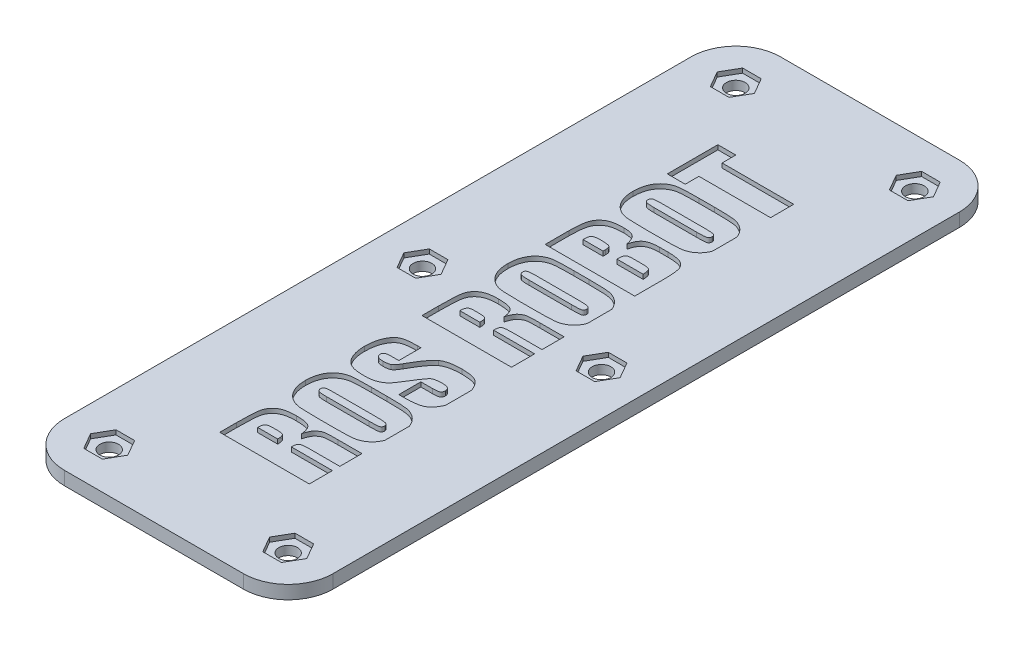
from build123d import *

# Parameters (mm, degrees)
SKETCH1_W           = 60
SKETCH1_H           = 160
BOSS_EXTRUDE1_DEPTH = 3
SKETCH2_R           = 2.09
CUT_EXTRUDE1_DEPTH  = 4
CUT_EXTRUDE2_DEPTH  = 1
FILLET1_R           = 10
CUT_EXTRUDE3_DEPTH  = 1


with BuildPart() as part:
    # Sketch1 → Boss-Extrude1 (new body)
    with BuildSketch(Plane(origin=(0, 0, 0), x_dir=(1, 0, 0), z_dir=(0, 1, 0))):
        Rectangle(SKETCH1_W, SKETCH1_H)
    extrude(amount=BOSS_EXTRUDE1_DEPTH)

    # Sketch2 → Cut-Extrude1 (cut, through all)
    with BuildSketch(Plane(origin=(0, 3, 0), x_dir=(1, 0, 0), z_dir=(0, 1, 0))):
        with Locations((-20, -70)):
            Circle(SKETCH2_R)
        with Locations((-20, 0)):
            Circle(SKETCH2_R)
        with Locations((-20, 70)):
            Circle(SKETCH2_R)
    cut_extrude1 = extrude(amount=-CUT_EXTRUDE1_DEPTH, mode=Mode.SUBTRACT)

    # Mirror1: Cut-Extrude1 across plane
    add(cut_extrude1.mirror(Plane(origin=(0, 0, 0), x_dir=(0, 0, 1), z_dir=(1, 0, 0))), mode=Mode.SUBTRACT)

    # Sketch3 → Cut-Extrude2 (cut)
    with BuildSketch(Plane(origin=(0, 3, 0), x_dir=(1, 0, 0), z_dir=(0, 1, 0))):
        with BuildLine():
            Line((-10, -55.294117647), (10, -55.294117647))
            Line((10, -55.294117647), (10, -50.117647059))
            Line((10, -50.117647059), (0.823529412, -50.117647059))
            add(Edge.make_bspline(
                [(3.235294118, -48.470588235), (2.989040814, -48.472629573), (2.639050732, -48.472609959), (2.199316231, -48.504803837), (1.926897066, -48.533164663), (1.692438703, -48.569281782), (1.49574074, -48.610523448), (1.339038243, -48.665722106), (1.214579141, -48.728929145), (1.113981631, -48.811228735), (1.03929987, -48.923342767), (0.966657804, -49.054244329), (0.919353851, -49.217915347), (0.873311477, -49.403659462), (0.835597841, -49.707286412), (0.823973747, -49.948124989), (0.823529412, -50.117647059)],
                knots=[0, 0, 0, 0, 0.208735031, 0.296167179, 0.37344265, 0.440694545, 0.497112652, 0.543415123, 0.581035154, 0.614932476, 0.652105749, 0.694367553, 0.74131732, 0.795712192, 0.856498699, 1, 1, 1, 1], degree=3))
            Line((3.235294118, -48.470588235), (10, -48.470588235))
            Line((10, -48.470588235), (10, -43.529411765))
            Line((10, -43.529411765), (4.658088235, -43.529411765))
            add(Edge.make_bspline(
                [(-0.573529412, -46.408088235), (-0.508186487, -46.169202547), (-0.415807847, -45.822748493), (-0.253576942, -45.392429256), (-0.12424053, -45.117359412), (0.008181693, -44.872188688), (0.146242268, -44.65674583), (0.298199184, -44.475211831), (0.505595072, -44.279090918), (0.769482386, -44.085338589), (1.073939288, -43.890136431), (1.366818297, -43.747197915), (1.616256033, -43.665317475), (1.84380423, -43.628386957), (2.070329283, -43.598146442), (2.357684941, -43.579047523), (2.703272021, -43.560390596), (3.107774826, -43.546616069), (3.76580814, -43.52957415), (4.289261909, -43.534840608), (4.658088235, -43.529411765)],
                knots=[0, 0, 0, 0, 0.110210274, 0.159198398, 0.204303993, 0.245275902, 0.283065073, 0.3178845, 0.350264175, 0.409777515, 0.463155522, 0.510931222, 0.554366277, 0.579275166, 0.613344402, 0.65597887, 0.707279948, 0.767268001, 0.835955663, 1, 1, 1, 1], degree=3))
            add(Edge.make_bspline(
                [(-4.617647059, -43.529411765), (-4.265347321, -43.523568214), (-3.759919224, -43.547429474), (-3.118182503, -43.602500182), (-2.707546117, -43.670971052), (-2.343153143, -43.74912541), (-2.023822753, -43.845927278), (-1.754303785, -43.967615545), (-1.524564876, -44.105726294), (-1.330409182, -44.274272382), (-1.160503413, -44.475701558), (-1.010392486, -44.712065683), (-0.880561748, -44.983524654), (-0.777601525, -45.29095197), (-0.646430718, -45.763349146), (-0.597468225, -46.144266225), (-0.573529412, -46.408088235)],
                knots=[0, 0, 0, 0, 0.183843892, 0.264214308, 0.336184648, 0.401092358, 0.45878306, 0.510056682, 0.55517248, 0.59828253, 0.64368343, 0.692329227, 0.744143255, 0.800414159, 0.861431347, 1, 1, 1, 1], degree=3))
            add(Edge.make_bspline(
                [(-10, -51.566176471), (-10.002073268, -50.993819944), (-9.992522011, -50.173782937), (-9.961770188, -49.130967301), (-9.934349846, -48.461579038), (-9.893765625, -47.867125834), (-9.846902044, -47.348485673), (-9.793813546, -46.905287107), (-9.727924289, -46.526534008), (-9.642203621, -46.192709029), (-9.529610049, -45.884608598), (-9.3956181, -45.589803188), (-9.228198446, -45.311726309), (-9.031642664, -45.052332013), (-8.815602269, -44.802348856), (-8.564597704, -44.574834978), (-8.290441128, -44.355921653), (-7.977684947, -44.158035206), (-7.6226227, -43.990685169), (-7.226287928, -43.847046859), (-6.786918244, -43.730527587), (-6.30511939, -43.640302786), (-5.579003966, -43.54780148), (-5.009887783, -43.534831682), (-4.617647059, -43.529411765)],
                knots=[0, 0, 0, 0, 0.148881435, 0.213302999, 0.271376625, 0.323137581, 0.368275921, 0.406826982, 0.439217091, 0.468211877, 0.496345732, 0.524443445, 0.552325136, 0.580568943, 0.609027807, 0.638127546, 0.668547056, 0.700208954, 0.734143472, 0.770447799, 0.809729999, 0.852243566, 0.897872275, 1, 1, 1, 1], degree=3))
            Line((-10, -51.566176471), (-10, -55.294117647))
        make_face()
        with BuildLine():
            Line((-2.235294118, -50.117647059), (-6.705882353, -50.117647059))
            add(Edge.make_bspline(
                [(-5.154411765, -48.470588235), (-5.418336948, -48.473249493), (-5.788234319, -48.491488459), (-6.208983424, -48.648984539), (-6.422021915, -48.813415334), (-6.552252293, -49.050216126), (-6.691331049, -49.479623299), (-6.700787332, -49.853765331), (-6.705882353, -50.117647059)],
                knots=[0, 0, 0, 0, 0.296724354, 0.405999103, 0.497474067, 0.590179394, 0.702696619, 1, 1, 1, 1], degree=3))
            Line((-5.154411765, -48.470588235), (-4.047794118, -48.470588235))
            add(Edge.make_bspline(
                [(-2.235294118, -50.117647059), (-2.2410209, -49.859031368), (-2.244911105, -49.494151793), (-2.359520163, -49.070270281), (-2.445519037, -48.867401357), (-2.55713594, -48.745711405), (-2.670238573, -48.667444045), (-2.820402185, -48.608189394), (-3.001543379, -48.557137957), (-3.215789469, -48.518214901), (-3.567218076, -48.475786698), (-3.849445649, -48.476158465), (-4.047794118, -48.470588235)],
                knots=[0, 0, 0, 0, 0.26299036, 0.361622752, 0.442866927, 0.481355846, 0.526610603, 0.580321924, 0.643299483, 0.716253842, 0.799640904, 1, 1, 1, 1], degree=3))
        make_face(mode=Mode.SUBTRACT)
        with BuildLine():
            add(Edge.make_bspline(
                [(10, -38.378083125), (9.980984118, -38.42752306), (9.878125419, -38.685696746), (9.665995506, -39.134570848), (9.29388391, -39.678742325), (8.86835261, -40.17166977), (8.369272434, -40.58621281), (7.832614548, -40.935288079), (7.264792336, -41.206088056), (6.674408532, -41.400035049), (6.156196354, -41.495437109), (5.704959011, -41.53554284), (5.307854377, -41.56519848), (4.85186231, -41.58999385), (4.338407042, -41.612881022), (3.765971372, -41.625929638), (2.887326127, -41.641512883), (2.198536957, -41.645759791), (1.720588235, -41.647058824)],
                knots=[0.224411446, 0.224411446, 0.224411446, 0.224411446, 0.237202779, 0.291504649, 0.343987522, 0.396025725, 0.44835046, 0.500180972, 0.550381919, 0.599920811, 0.649928359, 0.677302448, 0.709372201, 0.746150888, 0.787647262, 0.833562824, 0.884505076, 1, 1, 1, 1], degree=3))
            Line((10, -38.378083125), (10, -32.902336549))
            add(Edge.make_bspline(
                [(1.720588235, -29.647058824), (2.188717266, -29.651572048), (2.862792337, -29.648872672), (3.724400067, -29.662884644), (4.286760579, -29.683832297), (4.795587242, -29.69920585), (5.249009688, -29.725592699), (5.647384029, -29.754774686), (6.101645014, -29.796088836), (6.624952968, -29.881882502), (7.219368568, -30.068760168), (7.784773996, -30.331855104), (8.318358198, -30.667586355), (8.812591488, -31.069196806), (9.245882126, -31.546644343), (9.620320483, -32.087557394), (9.855282283, -32.552476311), (9.971898719, -32.831420628), (10, -32.902336549)],
                knots=[0, 0, 0, 0, 0.11310055, 0.162848353, 0.208171349, 0.249055911, 0.285827126, 0.317890363, 0.34555357, 0.396029061, 0.44565955, 0.495598169, 0.546282494, 0.597611279, 0.648954578, 0.701516088, 0.756070273, 0.774486187, 0.774486187, 0.774486187, 0.774486187], degree=3))
            Line((1.720588235, -29.647058824), (-1.720588235, -29.647058824))
            add(Edge.make_bspline(
                [(-10.470588235, -35.647058824), (-10.471351287, -35.137209972), (-10.409632236, -34.388756873), (-10.190714791, -33.431538295), (-9.959732893, -32.773857069), (-9.663969879, -32.163892001), (-9.296625615, -31.615746936), (-8.866737602, -31.126321609), (-8.369656032, -30.711070126), (-7.831550666, -30.363447758), (-7.265834752, -30.087017401), (-6.675361322, -29.895161748), (-6.158763212, -29.797784394), (-5.707221304, -29.759741225), (-5.309410488, -29.72270309), (-4.851678447, -29.706207961), (-4.338450104, -29.680281409), (-3.765909196, -29.669791107), (-2.887460519, -29.643396753), (-2.19844543, -29.654647793), (-1.720588235, -29.647058824)],
                knots=[0, 0, 0, 0, 0.123193932, 0.180662712, 0.236860689, 0.291295599, 0.344027448, 0.395846617, 0.448174423, 0.500007975, 0.550340105, 0.599881904, 0.6496013, 0.676976995, 0.709367001, 0.746132344, 0.787631153, 0.833549409, 0.884500674, 1, 1, 1, 1], degree=3))
            add(Edge.make_bspline(
                [(-1.720588235, -41.647058824), (-2.18748944, -41.642557679), (-2.861570976, -41.645251447), (-3.723168413, -41.631155192), (-4.286784378, -41.610726852), (-4.794223549, -41.593533221), (-5.247897112, -41.573074111), (-5.646130949, -41.54281222), (-6.101982975, -41.502445447), (-6.624469402, -41.410830594), (-7.219562523, -41.225936599), (-7.785214435, -40.960957455), (-8.32114813, -40.628805746), (-8.814079121, -40.223519767), (-9.24365518, -39.744493009), (-9.621260416, -39.206137847), (-9.928263659, -38.599940437), (-10.169329369, -37.935335754), (-10.413124021, -36.953580745), (-10.465199955, -36.175678629), (-10.470588235, -35.647058824)],
                knots=[0, 0, 0, 0, 0.112808074, 0.162853494, 0.208177932, 0.249063796, 0.285524951, 0.317884488, 0.345548575, 0.39607688, 0.445708948, 0.495649157, 0.546586122, 0.597688037, 0.649251897, 0.701571856, 0.756127778, 0.812891824, 0.872063415, 1, 1, 1, 1], degree=3))
            Line((-1.720588235, -41.647058824), (1.720588235, -41.647058824))
        make_face()
        with BuildLine():
            Line((4.566176471, -36.470588235), (-4.959558824, -36.470588235))
            add(Edge.make_bspline(
                [(-7.176470588, -35.621323529), (-7.182599475, -35.747366073), (-7.138920866, -35.933002361), (-7.00068513, -36.139309662), (-6.880311142, -36.245423973), (-6.748139917, -36.313371461), (-6.606004763, -36.354573761), (-6.426365541, -36.390296213), (-6.207497569, -36.417644724), (-5.951560006, -36.445256496), (-5.530709236, -36.461207551), (-5.196278933, -36.472961453), (-4.959558824, -36.470588235)],
                knots=[0, 0, 0, 0, 0.141229944, 0.207870292, 0.277367941, 0.319365436, 0.37439268, 0.443449943, 0.525666756, 0.622809696, 0.733417226, 1, 1, 1, 1], degree=3))
            add(Edge.make_bspline(
                [(-4.959558824, -34.823529412), (-5.175303354, -34.824206202), (-5.482932653, -34.830022252), (-5.871602904, -34.843021941), (-6.115480155, -34.862219357), (-6.32757554, -34.88386874), (-6.508580133, -34.907405438), (-6.655852623, -34.940578471), (-6.805984555, -34.986221663), (-6.954005969, -35.070163571), (-7.143059215, -35.268657855), (-7.172463444, -35.4859788), (-7.176470588, -35.621323529)],
                knots=[0, 0, 0, 0, 0.245381507, 0.350013726, 0.44228014, 0.523562531, 0.592561096, 0.649714338, 0.695120491, 0.770678918, 0.840725622, 1, 1, 1, 1], degree=3))
            Line((-4.959558824, -34.823529412), (4.415441176, -34.823529412))
            add(Edge.make_bspline(
                [(7.176470588, -35.658088235), (7.174783202, -35.509561683), (7.135583707, -35.26697932), (6.90741784, -35.058833937), (6.72767083, -34.978516656), (6.545782298, -34.931769144), (6.363187256, -34.905672215), (6.140129485, -34.879568932), (5.875332367, -34.857348446), (5.568703908, -34.844663241), (5.07734344, -34.828591774), (4.688733611, -34.824982941), (4.415441176, -34.823529412)],
                knots=[0, 0, 0, 0, 0.144508876, 0.209626381, 0.282206802, 0.327424738, 0.385694884, 0.455209163, 0.538351522, 0.635125416, 0.743352513, 1, 1, 1, 1], degree=3))
            add(Edge.make_bspline(
                [(4.566176471, -36.470588235), (4.834553498, -36.466064103), (5.215756676, -36.468857925), (5.695131762, -36.455213652), (5.990199181, -36.434073907), (6.243241553, -36.419382085), (6.454082367, -36.392829647), (6.62251498, -36.364986269), (6.78643941, -36.325211771), (6.945563097, -36.242673887), (7.143111825, -36.032036263), (7.175688722, -35.802728696), (7.176470588, -35.658088235)],
                knots=[0, 0, 0, 0, 0.263965983, 0.374910105, 0.471520145, 0.554902094, 0.624118814, 0.680393612, 0.722784308, 0.789641701, 0.853612109, 1, 1, 1, 1], degree=3))
        make_face(mode=Mode.SUBTRACT)
        with BuildLine():
            add(Edge.make_bspline(
                [(10, -24.797933282), (9.954712321, -24.921932371), (9.853998918, -25.178630702), (9.66764177, -25.54941368), (9.45914843, -25.909340871), (9.236781684, -26.239598194), (8.999069687, -26.536780418), (8.749649466, -26.802707831), (8.484081059, -27.036104581), (8.20217236, -27.235043433), (7.909621911, -27.406170353), (7.596805317, -27.538786556), (7.263292856, -27.650101611), (6.90106848, -27.745228003), (6.504964457, -27.819969672), (6.077327082, -27.887510977), (5.615954124, -27.937340123), (4.935999227, -27.987821131), (4.409444545, -27.999784328), (4.047794118, -28)],
                knots=[0.286193131, 0.286193131, 0.286193131, 0.286193131, 0.324638117, 0.36647626, 0.406957631, 0.445779823, 0.482361605, 0.517724123, 0.551885446, 0.58517537, 0.618126535, 0.650430981, 0.683967027, 0.720515684, 0.759451015, 0.801366796, 0.846634442, 0.894614826, 1, 1, 1, 1], degree=3))
            Line((10, -24.797933282), (10, -19.028387447))
            add(Edge.make_bspline(
                [(4.875, -16), (5.212235924, -15.998308673), (5.699832415, -16.013532504), (6.325640635, -16.070067848), (6.742235131, -16.122095276), (7.123627446, -16.196886289), (7.468984682, -16.283838341), (7.780065055, -16.385011418), (8.058285778, -16.508705216), (8.313949794, -16.656009443), (8.556973121, -16.827662161), (8.785816927, -17.033817412), (9.006723407, -17.265352113), (9.217895321, -17.528024577), (9.413112982, -17.823674404), (9.607942, -18.143294227), (9.805748963, -18.547089161), (9.932257587, -18.847030526), (10, -19.028387447)],
                knots=[0, 0, 0, 0, 0.107324697, 0.155096555, 0.199938691, 0.240857979, 0.278693097, 0.313224336, 0.344823203, 0.375394585, 0.406993451, 0.43931565, 0.473244831, 0.508753256, 0.546394925, 0.585922737, 0.62778092, 0.689366758, 0.689366758, 0.689366758, 0.689366758], degree=3))
            add(Edge.make_bspline(
                [(0.566176471, -16.9375), (0.806043702, -16.77003858), (1.211465721, -16.558891693), (1.810580448, -16.357268829), (2.324256078, -16.225991682), (2.890649038, -16.123687479), (3.744627839, -16.024389707), (4.413744653, -15.999987273), (4.875, -16)],
                knots=[0, 0, 0, 0, 0.19599711, 0.304678492, 0.423526134, 0.551406495, 0.69050554, 1, 1, 1, 1], degree=3))
            add(Edge.make_bspline(
                [(-2.783088235, -21.529411765), (-2.473367773, -20.970305965), (-2.018375264, -20.172909867), (-1.388063598, -19.189740388), (-0.956308764, -18.573813667), (-0.552231412, -18.038870295), (-0.067679288, -17.480460132), (0.302443276, -17.119384349), (0.566176471, -16.9375)],
                knots=[0, 0, 0, 0, 0.335277756, 0.481299959, 0.612364063, 0.729738585, 0.83271341, 1, 1, 1, 1], degree=3))
            add(Edge.make_bspline(
                [(-4.007352941, -23.044117647), (-3.908726816, -22.995337919), (-3.763485988, -22.89204074), (-3.578339598, -22.716456053), (-3.431720611, -22.539134867), (-3.274066191, -22.334418219), (-3.049218613, -21.999638416), (-2.892754352, -21.722308394), (-2.783088235, -21.529411765)],
                knots=[0, 0, 0, 0, 0.16675308, 0.269572473, 0.387215686, 0.516181657, 0.662459423, 1, 1, 1, 1], degree=3))
            add(Edge.make_bspline(
                [(-5.573529412, -23.294117647), (-5.268536496, -23.296326908), (-4.735456987, -23.266606811), (-4.213860364, -23.143358219), (-4.007352941, -23.044117647)],
                knots=[0, 0, 0, 0, 0.572651319, 1, 1, 1, 1], degree=3))
            add(Edge.make_bspline(
                [(-7.176470588, -22.272058824), (-7.175318321, -22.422382216), (-7.133916453, -22.652559624), (-6.956363272, -22.898626556), (-6.777858689, -23.049357016), (-6.547345801, -23.163822977), (-6.142731079, -23.266997244), (-5.81087743, -23.300706927), (-5.573529412, -23.294117647)],
                knots=[0, 0, 0, 0, 0.212113464, 0.31285869, 0.41856281, 0.535755935, 0.669150346, 1, 1, 1, 1], degree=3))
            add(Edge.make_bspline(
                [(-5.463235294, -21.411764706), (-5.764999618, -21.411775508), (-6.172259272, -21.420944293), (-6.645795321, -21.504577171), (-6.867179393, -21.59295536), (-7.015763217, -21.718292422), (-7.143674268, -21.940278977), (-7.181903344, -22.135550089), (-7.176470588, -22.272058824)],
                knots=[0, 0, 0, 0, 0.412530825, 0.5543248, 0.654755758, 0.734265772, 0.814634242, 1, 1, 1, 1], degree=3))
            Line((-5.463235294, -21.411764706), (-3.882352941, -21.411764706))
            Line((-3.882352941, -21.411764706), (-3.882352941, -16.470588235))
            Line((-3.882352941, -16.470588235), (-4.6875, -16.470588235))
            add(Edge.make_bspline(
                [(-10.470588235, -22.433823529), (-10.468055857, -22.099065103), (-10.45338162, -21.605945973), (-10.383236947, -20.964085), (-10.310475123, -20.511039039), (-10.213647039, -20.077159513), (-10.102043994, -19.661176237), (-9.964067719, -19.266804184), (-9.811063405, -18.891644607), (-9.63946446, -18.542127161), (-9.456959463, -18.220290347), (-9.258542216, -17.933561399), (-9.061274222, -17.668635547), (-8.839161064, -17.446049206), (-8.616983988, -17.2427572), (-8.37698945, -17.07859539), (-8.122327288, -16.940479705), (-7.838398187, -16.830854873), (-7.51975516, -16.730671229), (-7.154877727, -16.652900468), (-6.748162271, -16.581526248), (-6.294893947, -16.532829805), (-5.603934436, -16.481907954), (-5.062596295, -16.470960066), (-4.6875, -16.470588235)],
                knots=[0, 0, 0, 0, 0.103074516, 0.1516425, 0.198645931, 0.244221725, 0.288418755, 0.331122695, 0.372729792, 0.413046579, 0.450895281, 0.486465125, 0.520340719, 0.552350623, 0.583079291, 0.612898617, 0.641587226, 0.672055515, 0.706414833, 0.744299228, 0.786776018, 0.833469693, 0.884529575, 1, 1, 1, 1], degree=3))
            add(Edge.make_bspline(
                [(-4.786764706, -28.235294118), (-5.148252189, -28.229904379), (-5.672108777, -28.222936356), (-6.342020821, -28.155500003), (-6.786560757, -28.091071009), (-7.192892425, -28.006245663), (-7.561802534, -27.906291969), (-7.889279126, -27.780339706), (-8.183003162, -27.639202273), (-8.448602585, -27.474416935), (-8.693163012, -27.285392797), (-8.929597443, -27.079329609), (-9.143134685, -26.842812469), (-9.347943873, -26.586901064), (-9.538843121, -26.308886347), (-9.71100803, -26.005284687), (-9.9259027, -25.56649327), (-10.146603568, -24.965093143), (-10.411380502, -23.885130997), (-10.470239671, -23.0240668), (-10.470588235, -22.433823529)],
                knots=[0, 0, 0, 0, 0.115094371, 0.166420003, 0.214115061, 0.257929727, 0.298417601, 0.335563099, 0.369390983, 0.401957355, 0.434786392, 0.467650138, 0.501587937, 0.535990613, 0.571893796, 0.608743473, 0.646930183, 0.727243377, 0.811970216, 1, 1, 1, 1], degree=3))
            add(Edge.make_bspline(
                [(1.323529412, -23.977941176), (1.131175782, -24.294407689), (0.853854405, -24.747091531), (0.486700712, -25.315444229), (0.246545695, -25.677903122), (0.023994059, -25.995249819), (-0.173199106, -26.270775338), (-0.348922133, -26.504176854), (-0.560178172, -26.756225593), (-0.838522668, -27.032061417), (-1.219833144, -27.321955364), (-1.657111427, -27.582564064), (-2.149901427, -27.816746262), (-2.707855507, -28.01086208), (-3.591829962, -28.187012068), (-4.29540431, -28.241859841), (-4.786764706, -28.235294118)],
                knots=[0, 0, 0, 0, 0.139505929, 0.199942303, 0.254866781, 0.303272613, 0.345933972, 0.382494964, 0.413288554, 0.469758671, 0.52967984, 0.593250504, 0.661184865, 0.734906166, 0.815121063, 1, 1, 1, 1], degree=3))
            add(Edge.make_bspline(
                [(3.125, -21.422794118), (3.006688611, -21.527846739), (2.832011809, -21.723714843), (2.59856985, -22.027378176), (2.386228715, -22.323150848), (2.145768995, -22.663696157), (1.785720161, -23.219010231), (1.514192243, -23.665593102), (1.323529412, -23.977941176)],
                knots=[0, 0, 0, 0, 0.151178731, 0.250672725, 0.366592017, 0.499698309, 0.649696987, 1, 1, 1, 1], degree=3))
            add(Edge.make_bspline(
                [(5.507352941, -20.941176471), (5.230081296, -20.940709092), (4.833506149, -20.953623972), (4.331545195, -21.000787275), (4.014448686, -21.058517267), (3.733424676, -21.119961985), (3.432091637, -21.228045492), (3.23105503, -21.330156307), (3.125, -21.422794118)],
                knots=[0, 0, 0, 0, 0.336680385, 0.481832826, 0.611778822, 0.728036552, 0.830669431, 1, 1, 1, 1], degree=3))
            add(Edge.make_bspline(
                [(7.176470588, -22.055147059), (7.179717402, -21.886459311), (7.131916095, -21.634584302), (6.943960215, -21.361763952), (6.7516419, -21.204657804), (6.511030871, -21.082668623), (6.094038912, -20.966808099), (5.749965053, -20.942035384), (5.507352941, -20.941176471)],
                knots=[0, 0, 0, 0, 0.223438647, 0.325746663, 0.431376903, 0.547857623, 0.679404012, 1, 1, 1, 1], degree=3))
            add(Edge.make_bspline(
                [(5.297794118, -23.058823529), (5.479444625, -23.061330484), (5.737799236, -23.049017381), (6.065711905, -23.033549614), (6.271102852, -23.004726), (6.451745816, -22.979951789), (6.603092758, -22.937095221), (6.730061315, -22.895293432), (6.862832994, -22.827664593), (6.993662718, -22.711681339), (7.150620917, -22.454353006), (7.172923046, -22.215061065), (7.176470588, -22.055147059)],
                knots=[0, 0, 0, 0, 0.221449353, 0.31585969, 0.400263121, 0.474516094, 0.538002798, 0.591926172, 0.637412015, 0.719012888, 0.801608182, 1, 1, 1, 1], degree=3))
            Line((5.297794118, -23.058823529), (2.705882353, -23.058823529))
            Line((2.705882353, -23.058823529), (2.705882353, -28))
            Line((2.705882353, -28), (4.047794118, -28))
        make_face()
        with BuildLine():
            Line((-10, -10.117647059), (10, -10.117647059))
            Line((10, -10.117647059), (10, -4.941176471))
            Line((10, -4.941176471), (0.823529412, -4.941176471))
            add(Edge.make_bspline(
                [(3.235294118, -3.294117647), (2.989040814, -3.296158985), (2.639050732, -3.296139371), (2.199316231, -3.328333249), (1.926897066, -3.356694074), (1.692438703, -3.392811194), (1.49574074, -3.43405286), (1.339038243, -3.489251518), (1.214579141, -3.552458557), (1.113981631, -3.634758147), (1.03929987, -3.746872179), (0.966657804, -3.877773741), (0.919353851, -4.041444759), (0.873311477, -4.227188874), (0.835597841, -4.530815824), (0.823973747, -4.771654401), (0.823529412, -4.941176471)],
                knots=[0, 0, 0, 0, 0.208735031, 0.296167179, 0.37344265, 0.440694545, 0.497112652, 0.543415123, 0.581035154, 0.614932476, 0.652105749, 0.694367553, 0.74131732, 0.795712192, 0.856498699, 1, 1, 1, 1], degree=3))
            Line((3.235294118, -3.294117647), (10, -3.294117647))
            Line((10, -3.294117647), (10, 1.647058824))
            Line((10, 1.647058824), (4.658088235, 1.647058824))
            add(Edge.make_bspline(
                [(-0.573529412, -1.231617647), (-0.508186487, -0.992731958), (-0.415807847, -0.646277905), (-0.253576942, -0.215958668), (-0.12424053, 0.059111176), (0.008181693, 0.3042819), (0.146242268, 0.519724758), (0.298199184, 0.701258757), (0.505595072, 0.89737967), (0.769482386, 1.091132), (1.073939288, 1.286334157), (1.366818297, 1.429272673), (1.616256033, 1.511153114), (1.84380423, 1.548083631), (2.070329283, 1.578324146), (2.357684941, 1.597423065), (2.703272021, 1.616079992), (3.107774826, 1.629854519), (3.76580814, 1.646896438), (4.289261909, 1.64162998), (4.658088235, 1.647058824)],
                knots=[0, 0, 0, 0, 0.110210274, 0.159198398, 0.204303993, 0.245275902, 0.283065073, 0.3178845, 0.350264175, 0.409777515, 0.463155522, 0.510931222, 0.554366277, 0.579275166, 0.613344402, 0.65597887, 0.707279948, 0.767268001, 0.835955663, 1, 1, 1, 1], degree=3))
            add(Edge.make_bspline(
                [(-4.617647059, 1.647058824), (-4.265347321, 1.652902374), (-3.759919224, 1.629041114), (-3.118182503, 1.573970406), (-2.707546117, 1.505499536), (-2.343153143, 1.427345178), (-2.023822753, 1.33054331), (-1.754303785, 1.208855044), (-1.524564876, 1.070744294), (-1.330409182, 0.902198206), (-1.160503413, 0.70076903), (-1.010392486, 0.464404905), (-0.880561748, 0.192945934), (-0.777601525, -0.114481382), (-0.646430718, -0.586878558), (-0.597468225, -0.967795637), (-0.573529412, -1.231617647)],
                knots=[0, 0, 0, 0, 0.183843892, 0.264214308, 0.336184648, 0.401092358, 0.45878306, 0.510056682, 0.55517248, 0.59828253, 0.64368343, 0.692329227, 0.744143255, 0.800414159, 0.861431347, 1, 1, 1, 1], degree=3))
            add(Edge.make_bspline(
                [(-10, -6.389705882), (-10.002073268, -5.817349355), (-9.992522011, -4.997312349), (-9.961770188, -3.954496712), (-9.934349846, -3.28510845), (-9.893765625, -2.690655246), (-9.846902044, -2.172015085), (-9.793813546, -1.728816518), (-9.727924289, -1.35006342), (-9.642203621, -1.016238441), (-9.529610049, -0.70813801), (-9.3956181, -0.4133326), (-9.228198446, -0.135255721), (-9.031642664, 0.124138575), (-8.815602269, 0.374121732), (-8.564597704, 0.60163561), (-8.290441128, 0.820548935), (-7.977684947, 1.018435383), (-7.6226227, 1.185785419), (-7.226287928, 1.329423729), (-6.786918244, 1.445943001), (-6.30511939, 1.536167802), (-5.579003966, 1.628669108), (-5.009887783, 1.641638907), (-4.617647059, 1.647058824)],
                knots=[0, 0, 0, 0, 0.148881435, 0.213302999, 0.271376625, 0.323137581, 0.368275921, 0.406826982, 0.439217091, 0.468211877, 0.496345732, 0.524443445, 0.552325136, 0.580568943, 0.609027807, 0.638127546, 0.668547056, 0.700208954, 0.734143472, 0.770447799, 0.809729999, 0.852243566, 0.897872275, 1, 1, 1, 1], degree=3))
            Line((-10, -6.389705882), (-10, -10.117647059))
        make_face()
        with BuildLine():
            Line((-2.235294118, -4.941176471), (-6.705882353, -4.941176471))
            add(Edge.make_bspline(
                [(-5.154411765, -3.294117647), (-5.418336948, -3.296778905), (-5.788234319, -3.315017871), (-6.208983424, -3.472513951), (-6.422021915, -3.636944745), (-6.552252293, -3.873745538), (-6.691331049, -4.303152711), (-6.700787332, -4.677294743), (-6.705882353, -4.941176471)],
                knots=[0, 0, 0, 0, 0.296724354, 0.405999103, 0.497474067, 0.590179394, 0.702696619, 1, 1, 1, 1], degree=3))
            Line((-5.154411765, -3.294117647), (-4.047794118, -3.294117647))
            add(Edge.make_bspline(
                [(-2.235294118, -4.941176471), (-2.2410209, -4.68256078), (-2.244911105, -4.317681205), (-2.359520163, -3.893799693), (-2.445519037, -3.690930769), (-2.55713594, -3.569240816), (-2.670238573, -3.490973456), (-2.820402185, -3.431718806), (-3.001543379, -3.380667369), (-3.215789469, -3.341744313), (-3.567218076, -3.29931611), (-3.849445649, -3.299687877), (-4.047794118, -3.294117647)],
                knots=[0, 0, 0, 0, 0.26299036, 0.361622752, 0.442866927, 0.481355846, 0.526610603, 0.580321924, 0.643299483, 0.716253842, 0.799640904, 1, 1, 1, 1], degree=3))
        make_face(mode=Mode.SUBTRACT)
        with BuildLine():
            add(Edge.make_bspline(
                [(10, 6.798387464), (9.980984118, 6.748947528), (9.878125419, 6.490773842), (9.665995506, 6.04189974), (9.29388391, 5.497728263), (8.86835261, 5.004800818), (8.369272434, 4.590257778), (7.832614548, 4.241182509), (7.264792336, 3.970382533), (6.674408532, 3.776435539), (6.156196354, 3.68103348), (5.704959011, 3.640927748), (5.307854377, 3.611272108), (4.85186231, 3.586476739), (4.338407042, 3.563589566), (3.765971372, 3.55054095), (2.887326127, 3.534957706), (2.198536957, 3.530710798), (1.720588235, 3.529411765)],
                knots=[0.224411446, 0.224411446, 0.224411446, 0.224411446, 0.237202779, 0.291504649, 0.343987522, 0.396025725, 0.44835046, 0.500180972, 0.550381919, 0.599920811, 0.649928359, 0.677302448, 0.709372201, 0.746150888, 0.787647262, 0.833562824, 0.884505076, 1, 1, 1, 1], degree=3))
            Line((10, 6.798387464), (10, 12.27413404))
            add(Edge.make_bspline(
                [(1.720588235, 15.529411765), (2.188717266, 15.524898541), (2.862792337, 15.527597916), (3.724400067, 15.513585944), (4.286760579, 15.492638291), (4.795587242, 15.477264739), (5.249009688, 15.450877889), (5.647384029, 15.421695902), (6.101645014, 15.380381753), (6.624952968, 15.294588086), (7.219368568, 15.107710421), (7.784773996, 14.844615484), (8.318358198, 14.508884233), (8.812591488, 14.107273783), (9.245882126, 13.629826245), (9.620320483, 13.088913194), (9.855282283, 12.623994277), (9.971898719, 12.34504996), (10, 12.27413404)],
                knots=[0, 0, 0, 0, 0.11310055, 0.162848353, 0.208171349, 0.249055911, 0.285827126, 0.317890363, 0.34555357, 0.396029061, 0.44565955, 0.495598169, 0.546282494, 0.597611279, 0.648954578, 0.701516088, 0.756070273, 0.774486187, 0.774486187, 0.774486187, 0.774486187], degree=3))
            Line((1.720588235, 15.529411765), (-1.720588235, 15.529411765))
            add(Edge.make_bspline(
                [(-10.470588235, 9.529411765), (-10.471351287, 10.039260617), (-10.409632236, 10.787713715), (-10.190714791, 11.744932293), (-9.959732893, 12.402613519), (-9.663969879, 13.012578587), (-9.296625615, 13.560723652), (-8.866737602, 14.050148979), (-8.369656032, 14.465400462), (-7.831550666, 14.81302283), (-7.265834752, 15.089453187), (-6.675361322, 15.281308841), (-6.158763212, 15.378686195), (-5.707221304, 15.416729364), (-5.309410488, 15.453767498), (-4.851678447, 15.470262627), (-4.338450104, 15.496189179), (-3.765909196, 15.506679481), (-2.887460519, 15.533073835), (-2.19844543, 15.521822795), (-1.720588235, 15.529411765)],
                knots=[0, 0, 0, 0, 0.123193932, 0.180662712, 0.236860689, 0.291295599, 0.344027448, 0.395846617, 0.448174423, 0.500007975, 0.550340105, 0.599881904, 0.6496013, 0.676976995, 0.709367001, 0.746132344, 0.787631153, 0.833549409, 0.884500674, 1, 1, 1, 1], degree=3))
            add(Edge.make_bspline(
                [(-1.720588235, 3.529411765), (-2.18748944, 3.53391291), (-2.861570976, 3.531219141), (-3.723168413, 3.545315397), (-4.286784378, 3.565743736), (-4.794223549, 3.582937367), (-5.247897112, 3.603396478), (-5.646130949, 3.633658368), (-6.101982975, 3.674025142), (-6.624469402, 3.765639994), (-7.219562523, 3.950533989), (-7.785214435, 4.215513133), (-8.32114813, 4.547664842), (-8.814079121, 4.952950822), (-9.24365518, 5.431977579), (-9.621260416, 5.970332741), (-9.928263659, 6.576530151), (-10.169329369, 7.241134834), (-10.413124021, 8.222889843), (-10.465199955, 9.000791959), (-10.470588235, 9.529411765)],
                knots=[0, 0, 0, 0, 0.112808074, 0.162853494, 0.208177932, 0.249063796, 0.285524951, 0.317884488, 0.345548575, 0.39607688, 0.445708948, 0.495649157, 0.546586122, 0.597688037, 0.649251897, 0.701571856, 0.756127778, 0.812891824, 0.872063415, 1, 1, 1, 1], degree=3))
            Line((-1.720588235, 3.529411765), (1.720588235, 3.529411765))
        make_face()
        with BuildLine():
            Line((4.566176471, 8.705882353), (-4.959558824, 8.705882353))
            add(Edge.make_bspline(
                [(-7.176470588, 9.555147059), (-7.182599475, 9.429104515), (-7.138920866, 9.243468227), (-7.00068513, 9.037160926), (-6.880311142, 8.931046616), (-6.748139917, 8.863099127), (-6.606004763, 8.821896827), (-6.426365541, 8.786174375), (-6.207497569, 8.758825864), (-5.951560006, 8.731214092), (-5.530709236, 8.715263037), (-5.196278933, 8.703509135), (-4.959558824, 8.705882353)],
                knots=[0, 0, 0, 0, 0.141229944, 0.207870292, 0.277367941, 0.319365436, 0.37439268, 0.443449943, 0.525666756, 0.622809696, 0.733417226, 1, 1, 1, 1], degree=3))
            add(Edge.make_bspline(
                [(-4.959558824, 10.352941176), (-5.175303354, 10.352264386), (-5.482932653, 10.346448336), (-5.871602904, 10.333448647), (-6.115480155, 10.314251231), (-6.32757554, 10.292601849), (-6.508580133, 10.26906515), (-6.655852623, 10.235892117), (-6.805984555, 10.190248925), (-6.954005969, 10.106307017), (-7.143059215, 9.907812734), (-7.172463444, 9.690491789), (-7.176470588, 9.555147059)],
                knots=[0, 0, 0, 0, 0.245381507, 0.350013726, 0.44228014, 0.523562531, 0.592561096, 0.649714338, 0.695120491, 0.770678918, 0.840725622, 1, 1, 1, 1], degree=3))
            Line((-4.959558824, 10.352941176), (4.415441176, 10.352941176))
            add(Edge.make_bspline(
                [(7.176470588, 9.518382353), (7.174783202, 9.666908905), (7.135583707, 9.909491269), (6.90741784, 10.117636651), (6.72767083, 10.197953932), (6.545782298, 10.244701444), (6.363187256, 10.270798373), (6.140129485, 10.296901656), (5.875332367, 10.319122143), (5.568703908, 10.331807347), (5.07734344, 10.347878814), (4.688733611, 10.351487647), (4.415441176, 10.352941176)],
                knots=[0, 0, 0, 0, 0.144508876, 0.209626381, 0.282206802, 0.327424738, 0.385694884, 0.455209163, 0.538351522, 0.635125416, 0.743352513, 1, 1, 1, 1], degree=3))
            add(Edge.make_bspline(
                [(4.566176471, 8.705882353), (4.834553498, 8.710406485), (5.215756676, 8.707612663), (5.695131762, 8.721256936), (5.990199181, 8.742396681), (6.243241553, 8.757088503), (6.454082367, 8.783640941), (6.62251498, 8.811484319), (6.78643941, 8.851258818), (6.945563097, 8.933796701), (7.143111825, 9.144434325), (7.175688722, 9.373741892), (7.176470588, 9.518382353)],
                knots=[0, 0, 0, 0, 0.263965983, 0.374910105, 0.471520145, 0.554902094, 0.624118814, 0.680393612, 0.722784308, 0.789641701, 0.853612109, 1, 1, 1, 1], degree=3))
        make_face(mode=Mode.SUBTRACT)
        with BuildLine():
            Line((-10, 17.411764706), (10, 17.411764706))
            Line((10, 17.411764706), (10, 23.492647059))
            add(Edge.make_bspline(
                [(5.242647059, 29.647058824), (5.562644532, 29.646812462), (6.026827764, 29.635192846), (6.623446822, 29.584586988), (7.021215228, 29.534951021), (7.385674001, 29.468197782), (7.716316083, 29.388564201), (8.015408276, 29.293780096), (8.363234175, 29.14960596), (8.74665424, 28.927366376), (9.131049832, 28.58171603), (9.433497549, 28.164193669), (9.621221942, 27.757535454), (9.729179675, 27.375531482), (9.802121909, 27.017947482), (9.861860948, 26.594226079), (9.913076125, 26.102472039), (9.951814242, 25.545753948), (9.994365669, 24.668447698), (9.994351205, 23.976648658), (10, 23.492647059)],
                knots=[0, 0, 0, 0, 0.102268902, 0.148252963, 0.191287831, 0.230306444, 0.266587991, 0.299901488, 0.330446165, 0.386794172, 0.440584461, 0.494394702, 0.550463064, 0.582683787, 0.621084401, 0.666995037, 0.719365379, 0.779044003, 0.845298245, 1, 1, 1, 1], degree=3))
            Line((5.242647059, 29.647058824), (3.363970588, 29.647058824))
            add(Edge.make_bspline(
                [(-0.941176471, 26.632352941), (-0.878335362, 26.90637568), (-0.765762115, 27.300700064), (-0.56288787, 27.787632125), (-0.402673098, 28.106896555), (-0.22051409, 28.387346881), (-0.026797613, 28.636657687), (0.187839066, 28.84865708), (0.425229115, 29.024980417), (0.68715419, 29.172098002), (0.975506704, 29.302524236), (1.296825083, 29.40661881), (1.648075843, 29.494987923), (2.031115772, 29.56500852), (2.606138526, 29.628167049), (3.054773253, 29.646098611), (3.363970588, 29.647058824)],
                knots=[0, 0, 0, 0, 0.144042592, 0.209308729, 0.269932359, 0.32668049, 0.38029181, 0.431325131, 0.480651429, 0.531246854, 0.584898562, 0.642449522, 0.703940699, 0.770287073, 0.84166898, 1, 1, 1, 1], degree=3))
            add(Edge.make_bspline(
                [(-4.393382353, 29.411764706), (-4.126990133, 29.41598386), (-3.743106544, 29.396222444), (-3.256066937, 29.334964148), (-2.937604777, 29.279879292), (-2.653622433, 29.196253765), (-2.398933419, 29.104626632), (-2.178448506, 28.988432112), (-1.984982888, 28.854388338), (-1.816338677, 28.689065406), (-1.655843197, 28.498171445), (-1.516177065, 28.26689136), (-1.378311297, 28.007448391), (-1.248919057, 27.713445555), (-1.096259944, 27.252695911), (-0.993792729, 26.888687302), (-0.941176471, 26.632352941)],
                knots=[0, 0, 0, 0, 0.159635238, 0.229971647, 0.294226611, 0.35304997, 0.407212491, 0.456168779, 0.502023537, 0.547742778, 0.59730697, 0.651109669, 0.709268858, 0.77341036, 0.843331301, 1, 1, 1, 1], degree=3))
            add(Edge.make_bspline(
                [(-10, 22.716911765), (-9.995453326, 23.110291275), (-9.992088598, 23.681900263), (-9.952686927, 24.418555323), (-9.907114319, 24.913515961), (-9.856950367, 25.371064597), (-9.796114632, 25.791058651), (-9.718840383, 26.172456155), (-9.630921893, 26.520669601), (-9.523713394, 26.8423759), (-9.391200269, 27.143434389), (-9.23545347, 27.428259898), (-9.058703752, 27.698735988), (-8.855241863, 27.953140614), (-8.627607062, 28.191746973), (-8.374983504, 28.413745054), (-8.097680328, 28.621705733), (-7.786202266, 28.812643321), (-7.430102042, 28.973365406), (-7.029330489, 29.108122433), (-6.587251999, 29.22181161), (-6.099989949, 29.30427764), (-5.366465202, 29.389442028), (-4.791042127, 29.41614622), (-4.393382353, 29.411764706)],
                knots=[0, 0, 0, 0, 0.114375021, 0.166108066, 0.214389793, 0.258843936, 0.299904114, 0.337700596, 0.371916123, 0.404247528, 0.436150213, 0.467395744, 0.49851919, 0.529953016, 0.56195301, 0.594258892, 0.62760283, 0.662610335, 0.70023013, 0.740899013, 0.785395956, 0.832776928, 0.884431414, 1, 1, 1, 1], degree=3))
            Line((-10, 22.716911765), (-10, 17.411764706))
        make_face()
        with BuildLine():
            Line((-2.235294118, 22.588235294), (-6.705882353, 22.588235294))
            add(Edge.make_bspline(
                [(-4.794117647, 24.470588235), (-5.062170788, 24.473601667), (-5.431207161, 24.454740397), (-5.874896836, 24.37769061), (-6.108912695, 24.290930564), (-6.287926206, 24.18512451), (-6.427443444, 24.065629164), (-6.534581346, 23.932108827), (-6.604626234, 23.771096089), (-6.646964318, 23.56915724), (-6.693594331, 23.171954452), (-6.70169016, 22.835840711), (-6.705882353, 22.588235294)],
                knots=[0, 0, 0, 0, 0.246773781, 0.340005048, 0.413618877, 0.475394665, 0.530632455, 0.582131195, 0.631661098, 0.690822181, 0.771635832, 1, 1, 1, 1], degree=3))
            add(Edge.make_bspline(
                [(-2.246323529, 23.161764706), (-2.243112667, 23.394000556), (-2.271126629, 23.720444106), (-2.440251538, 24.083575852), (-2.592544184, 24.230993467), (-2.752742071, 24.301053962), (-2.914078937, 24.349390316), (-3.120807287, 24.381402351), (-3.370568825, 24.415860115), (-3.663910927, 24.439841122), (-4.142980969, 24.465850417), (-4.524499949, 24.47015933), (-4.794117647, 24.470588235)],
                knots=[0, 0, 0, 0, 0.207117208, 0.283923184, 0.350830951, 0.389245474, 0.438074134, 0.499906873, 0.574464838, 0.661754019, 0.760816726, 1, 1, 1, 1], degree=3))
            add(Edge.make_bspline(
                [(-2.235294118, 22.588235294), (-2.242972169, 22.874959549), (-2.246323529, 23.161764706)],
                knots=[0, 0, 0, 1, 1, 1], degree=2))
        make_face(mode=Mode.SUBTRACT)
        with BuildLine():
            Line((6.705882353, 22.588235294), (0.823529412, 22.588235294))
            add(Edge.make_bspline(
                [(2.783088235, 24.470588235), (2.580992751, 24.470303896), (2.291650025, 24.467503211), (1.931159289, 24.42775611), (1.707540562, 24.403304673), (1.520190342, 24.3573331), (1.363179519, 24.308705054), (1.24024349, 24.246433972), (1.143526711, 24.173634658), (1.073281433, 24.075604763), (1.016524158, 23.952965692), (0.965155439, 23.800026496), (0.922704046, 23.616434295), (0.886469189, 23.402786296), (0.845490318, 23.057438026), (0.830566506, 22.78210724), (0.823529412, 22.588235294)],
                knots=[0, 0, 0, 0, 0.18234372, 0.260036521, 0.32688627, 0.384748242, 0.433641625, 0.474638114, 0.508443963, 0.541575631, 0.582078258, 0.629925201, 0.686712704, 0.751712351, 0.82513553, 1, 1, 1, 1], degree=3))
            Line((2.783088235, 24.470588235), (4.746323529, 24.470588235))
            add(Edge.make_bspline(
                [(6.705882353, 22.588235294), (6.697406962, 22.77211117), (6.686457896, 23.035946827), (6.639035104, 23.366082296), (6.600446576, 23.57431779), (6.548534374, 23.75473471), (6.491147804, 23.909241382), (6.426347677, 24.037580991), (6.345277665, 24.139521751), (6.242531072, 24.219815984), (6.116989222, 24.290513523), (5.958992317, 24.342371017), (5.774048501, 24.391465703), (5.558475797, 24.426125537), (5.212916143, 24.460777173), (4.93906262, 24.475126558), (4.746323529, 24.470588235)],
                knots=[0, 0, 0, 0, 0.168583806, 0.241049478, 0.305039014, 0.362178465, 0.412572109, 0.455707222, 0.493180931, 0.530654639, 0.574325613, 0.624331078, 0.682257189, 0.749354057, 0.823771208, 1, 1, 1, 1], degree=3))
        make_face(mode=Mode.SUBTRACT)
        with BuildLine():
            add(Edge.make_bspline(
                [(10, 34.798387464), (9.980984118, 34.748947528), (9.878125419, 34.490773842), (9.665995506, 34.04189974), (9.29388391, 33.497728263), (8.86835261, 33.004800818), (8.369272434, 32.590257778), (7.832614548, 32.241182509), (7.264792336, 31.970382533), (6.674408532, 31.776435539), (6.156196354, 31.68103348), (5.704959011, 31.640927748), (5.307854377, 31.611272108), (4.85186231, 31.586476739), (4.338407042, 31.563589566), (3.765971372, 31.55054095), (2.887326127, 31.534957706), (2.198536957, 31.530710798), (1.720588235, 31.529411765)],
                knots=[0.224411446, 0.224411446, 0.224411446, 0.224411446, 0.237202779, 0.291504649, 0.343987522, 0.396025725, 0.44835046, 0.500180972, 0.550381919, 0.599920811, 0.649928359, 0.677302448, 0.709372201, 0.746150888, 0.787647262, 0.833562824, 0.884505076, 1, 1, 1, 1], degree=3))
            Line((10, 34.798387464), (10, 40.27413404))
            add(Edge.make_bspline(
                [(1.720588235, 43.529411765), (2.188717266, 43.524898541), (2.862792337, 43.527597916), (3.724400067, 43.513585944), (4.286760579, 43.492638291), (4.795587242, 43.477264739), (5.249009688, 43.450877889), (5.647384029, 43.421695902), (6.101645014, 43.380381753), (6.624952968, 43.294588086), (7.219368568, 43.107710421), (7.784773996, 42.844615484), (8.318358198, 42.508884233), (8.812591488, 42.107273783), (9.245882126, 41.629826245), (9.620320483, 41.088913194), (9.855282283, 40.623994277), (9.971898719, 40.34504996), (10, 40.27413404)],
                knots=[0, 0, 0, 0, 0.11310055, 0.162848353, 0.208171349, 0.249055911, 0.285827126, 0.317890363, 0.34555357, 0.396029061, 0.44565955, 0.495598169, 0.546282494, 0.597611279, 0.648954578, 0.701516088, 0.756070273, 0.774486187, 0.774486187, 0.774486187, 0.774486187], degree=3))
            Line((1.720588235, 43.529411765), (-1.720588235, 43.529411765))
            add(Edge.make_bspline(
                [(-10.470588235, 37.529411765), (-10.471351287, 38.039260617), (-10.409632236, 38.787713715), (-10.190714791, 39.744932293), (-9.959732893, 40.402613519), (-9.663969879, 41.012578587), (-9.296625615, 41.560723652), (-8.866737602, 42.050148979), (-8.369656032, 42.465400462), (-7.831550666, 42.81302283), (-7.265834752, 43.089453187), (-6.675361322, 43.281308841), (-6.158763212, 43.378686195), (-5.707221304, 43.416729364), (-5.309410488, 43.453767498), (-4.851678447, 43.470262627), (-4.338450104, 43.496189179), (-3.765909196, 43.506679481), (-2.887460519, 43.533073835), (-2.19844543, 43.521822795), (-1.720588235, 43.529411765)],
                knots=[0, 0, 0, 0, 0.123193932, 0.180662712, 0.236860689, 0.291295599, 0.344027448, 0.395846617, 0.448174423, 0.500007975, 0.550340105, 0.599881904, 0.6496013, 0.676976995, 0.709367001, 0.746132344, 0.787631153, 0.833549409, 0.884500674, 1, 1, 1, 1], degree=3))
            add(Edge.make_bspline(
                [(-1.720588235, 31.529411765), (-2.18748944, 31.53391291), (-2.861570976, 31.531219141), (-3.723168413, 31.545315397), (-4.286784378, 31.565743736), (-4.794223549, 31.582937367), (-5.247897112, 31.603396478), (-5.646130949, 31.633658368), (-6.101982975, 31.674025142), (-6.624469402, 31.765639994), (-7.219562523, 31.950533989), (-7.785214435, 32.215513133), (-8.32114813, 32.547664842), (-8.814079121, 32.952950822), (-9.24365518, 33.431977579), (-9.621260416, 33.970332741), (-9.928263659, 34.576530151), (-10.169329369, 35.241134834), (-10.413124021, 36.222889843), (-10.465199955, 37.000791959), (-10.470588235, 37.529411765)],
                knots=[0, 0, 0, 0, 0.112808074, 0.162853494, 0.208177932, 0.249063796, 0.285524951, 0.317884488, 0.345548575, 0.39607688, 0.445708948, 0.495649157, 0.546586122, 0.597688037, 0.649251897, 0.701571856, 0.756127778, 0.812891824, 0.872063415, 1, 1, 1, 1], degree=3))
            Line((-1.720588235, 31.529411765), (1.720588235, 31.529411765))
        make_face()
        with BuildLine():
            Line((4.566176471, 36.705882353), (-4.959558824, 36.705882353))
            add(Edge.make_bspline(
                [(-7.176470588, 37.555147059), (-7.182599475, 37.429104515), (-7.138920866, 37.243468227), (-7.00068513, 37.037160926), (-6.880311142, 36.931046616), (-6.748139917, 36.863099127), (-6.606004763, 36.821896827), (-6.426365541, 36.786174375), (-6.207497569, 36.758825864), (-5.951560006, 36.731214092), (-5.530709236, 36.715263037), (-5.196278933, 36.703509135), (-4.959558824, 36.705882353)],
                knots=[0, 0, 0, 0, 0.141229944, 0.207870292, 0.277367941, 0.319365436, 0.37439268, 0.443449943, 0.525666756, 0.622809696, 0.733417226, 1, 1, 1, 1], degree=3))
            add(Edge.make_bspline(
                [(-4.959558824, 38.352941176), (-5.175303354, 38.352264386), (-5.482932653, 38.346448336), (-5.871602904, 38.333448647), (-6.115480155, 38.314251231), (-6.32757554, 38.292601849), (-6.508580133, 38.26906515), (-6.655852623, 38.235892117), (-6.805984555, 38.190248925), (-6.954005969, 38.106307017), (-7.143059215, 37.907812734), (-7.172463444, 37.690491789), (-7.176470588, 37.555147059)],
                knots=[0, 0, 0, 0, 0.245381507, 0.350013726, 0.44228014, 0.523562531, 0.592561096, 0.649714338, 0.695120491, 0.770678918, 0.840725622, 1, 1, 1, 1], degree=3))
            Line((-4.959558824, 38.352941176), (4.415441176, 38.352941176))
            add(Edge.make_bspline(
                [(7.176470588, 37.518382353), (7.174783202, 37.666908905), (7.135583707, 37.909491269), (6.90741784, 38.117636651), (6.72767083, 38.197953932), (6.545782298, 38.244701444), (6.363187256, 38.270798373), (6.140129485, 38.296901656), (5.875332367, 38.319122143), (5.568703908, 38.331807347), (5.07734344, 38.347878814), (4.688733611, 38.351487647), (4.415441176, 38.352941176)],
                knots=[0, 0, 0, 0, 0.144508876, 0.209626381, 0.282206802, 0.327424738, 0.385694884, 0.455209163, 0.538351522, 0.635125416, 0.743352513, 1, 1, 1, 1], degree=3))
            add(Edge.make_bspline(
                [(4.566176471, 36.705882353), (4.834553498, 36.710406485), (5.215756676, 36.707612663), (5.695131762, 36.721256936), (5.990199181, 36.742396681), (6.243241553, 36.757088503), (6.454082367, 36.783640941), (6.62251498, 36.811484319), (6.78643941, 36.851258818), (6.945563097, 36.933796701), (7.143111825, 37.144434325), (7.175688722, 37.373741892), (7.176470588, 37.518382353)],
                knots=[0, 0, 0, 0, 0.263965983, 0.374910105, 0.471520145, 0.554902094, 0.624118814, 0.680393612, 0.722784308, 0.789641701, 0.853612109, 1, 1, 1, 1], degree=3))
        make_face(mode=Mode.SUBTRACT)
        Polygon((-6, 47.764705882), (10, 47.764705882), (10, 52.941176471), (-6, 52.941176471), (-6, 56), (-10, 56), (-10, 44.705882353), (-6, 44.705882353), align=None)
    extrude(amount=-CUT_EXTRUDE2_DEPTH, mode=Mode.SUBTRACT)

    # Fillet1
    fillet1_edges = [part.edges().sort_by_distance(p)[0] for p in [
        (30, 1.5, 80),
        (-30, 1.5, 80),
        (-30, 1.5, -80),
        (30, 1.5, -80),
    ]]
    fillet(fillet1_edges, radius=FILLET1_R)

    # Sketch4 → Cut-Extrude3 (cut)
    with BuildSketch(Plane(origin=(0, 3, 0), x_dir=(1, 0, 0), z_dir=(0, 1, 0))):
        Polygon((24.156921938, -70), (22.078460969, -66.4), (17.921539031, -66.4), (15.843078062, -70), (17.921539031, -73.6), (22.078460969, -73.6), align=None)
        Polygon((24.156921938, 0), (22.078460969, 3.6), (17.921539031, 3.6), (15.843078062, 0), (17.921539031, -3.6), (22.078460969, -3.6), align=None)
        Polygon((24.156921938, 70), (22.078460969, 73.6), (17.921539031, 73.6), (15.843078062, 70), (17.921539031, 66.4), (22.078460969, 66.4), align=None)
    cut_extrude3 = extrude(amount=-CUT_EXTRUDE3_DEPTH, mode=Mode.SUBTRACT)

    # Mirror2: Cut-Extrude3 across plane
    add(cut_extrude3.mirror(Plane(origin=(0, 0, 0), x_dir=(0, 0, 1), z_dir=(1, 0, 0))), mode=Mode.SUBTRACT)


solid = part.part
